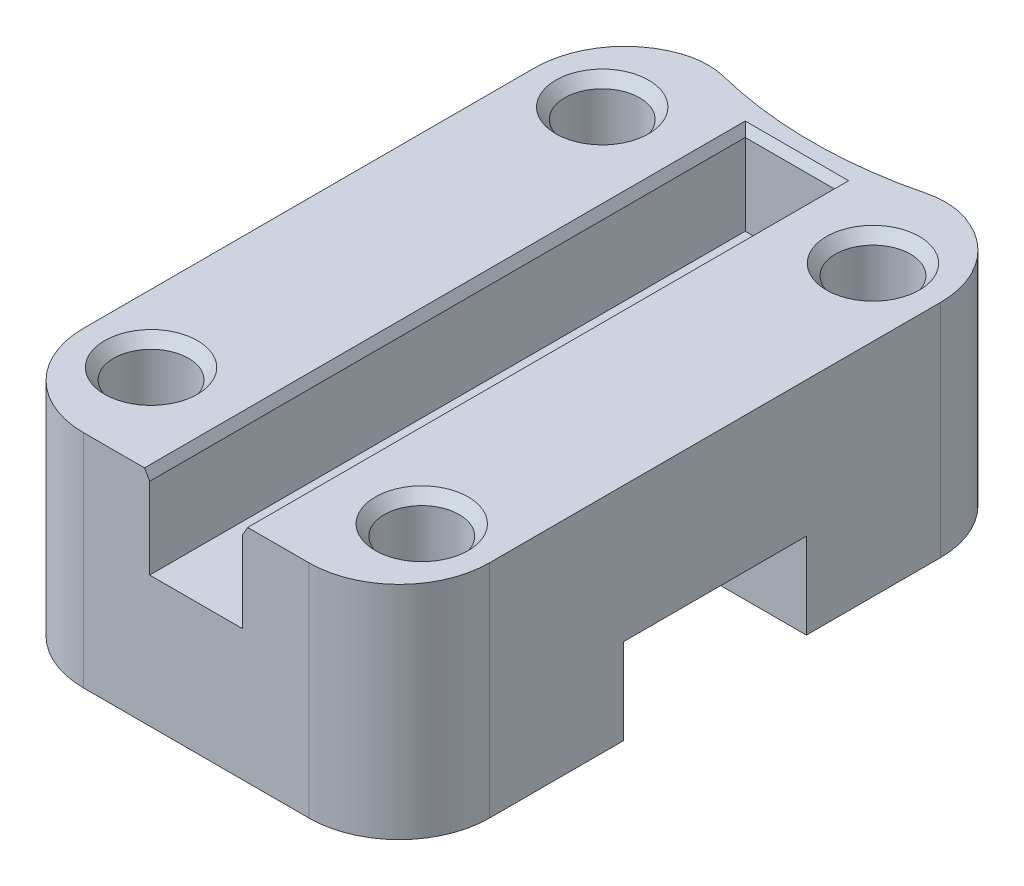
from build123d import *

# Parameters (mm, degrees)
SKETCH1_W               = 45
SKETCH1_H               = 70
BOSS_EXTRUDE1_DEPTH     = 14.5
SKETCH2_W               = 20.25
SKETCH2_H               = 9.5
CUT_EXTRUDE1_DEPTH      = 1
CUT_EXTRUDE1_DEPTH_BACK = 46
SKETCH3_R               = 4.15
CUT_EXTRUDE2_DEPTH      = 15.5
SKETCH5_R               = 4.15
BOSS_EXTRUDE2_DEPTH     = 10
CHAMFER1_SIZE           = 1
CHAMFER1_SIZE2          = 1.191753593
CHAMFER2_SIZE           = 1
CHAMFER2_SIZE2          = 0.577350269
CHAMFER2_PART_2_SIZE    = 1
CHAMFER2_PART_2_SIZE2   = 0.577350269
CHAMFER2_PART_3_SIZE    = 1
CHAMFER2_PART_3_SIZE2   = 0.577350269
FILLET1_R               = 10
CUT_EXTRUDE3_DEPTH      = 25.5
FILLET2_R               = 8


with BuildPart() as part:
    # Sketch1 → Boss-Extrude1 (new body)
    with BuildSketch(Plane(origin=(0, 0, 0), x_dir=(1, 0, 0), z_dir=(0, 1, 0))):
        Rectangle(SKETCH1_W, SKETCH1_H)
    extrude(amount=BOSS_EXTRUDE1_DEPTH)

    # Sketch2 → Cut-Extrude1 (cut, two sides)
    with BuildSketch(Plane(origin=(22.5, 0, 0), x_dir=(0, 0, -1), z_dir=(1, 0, 0))) as cut_extrude1_sk:
        with Locations((0, 4.75)):
            Rectangle(SKETCH2_W, SKETCH2_H)
    extrude(amount=CUT_EXTRUDE1_DEPTH, mode=Mode.SUBTRACT)
    extrude(cut_extrude1_sk.sketch, amount=-CUT_EXTRUDE1_DEPTH_BACK, mode=Mode.SUBTRACT)

    # Sketch3 → Cut-Extrude2 (cut, through all)
    with BuildSketch(Plane.XZ):
        with Locations((15, 25)):
            Circle(SKETCH3_R)
        with Locations((15, -25)):
            Circle(SKETCH3_R)
        with Locations((-15, -25)):
            Circle(SKETCH3_R)
        with Locations((-15, 25)):
            Circle(SKETCH3_R)
    extrude(amount=-CUT_EXTRUDE2_DEPTH, mode=Mode.SUBTRACT)

    # Sketch5 → Boss-Extrude2 (add)
    with BuildSketch(Plane(origin=(0, 14.5, 0), x_dir=(1, 0, 0), z_dir=(0, 1, 0))):
        Polygon((-5.15, -35), (-22.5, -35), (-22.5, 35), (22.5, 35), (22.5, -35), (5.15, -35), (5.130229348, -34.949305848), (5.15, 31), (-5.15, 31), align=None)
        with Locations((-15, 25)):
            Circle(SKETCH5_R, mode=Mode.SUBTRACT)
        with Locations((15, 25)):
            Circle(SKETCH5_R, mode=Mode.SUBTRACT)
        with Locations((15, -25)):
            Circle(SKETCH5_R, mode=Mode.SUBTRACT)
        with Locations((-15, -25)):
            Circle(SKETCH5_R, mode=Mode.SUBTRACT)
    extrude(amount=BOSS_EXTRUDE2_DEPTH)

    # Chamfer1
    chamfer1_edges = [part.edges().sort_by_distance(p)[0] for p in [
        (-19.15, 24.5, -25),
        (10.85, 24.5, -25),
        (10.85, 24.5, 25),
        (-19.15, 24.5, 25),
    ]]
    chamfer1_side = [part.faces().sort_by_distance(p)[0] for p in [
        (-13.825, 24.5, 34.167834151),
    ]]
    chamfer(chamfer1_edges, length=CHAMFER1_SIZE, length2=CHAMFER1_SIZE2, reference=chamfer1_side[0])

    # Chamfer2
    chamfer2_edges = [part.edges().sort_by_distance(p)[0] for p in [
        (-5.15, 24.5, 2),
    ]]
    chamfer2_side = [part.faces().sort_by_distance(p)[0] for p in [
        (-5.15, 19.5, 2),
    ]]
    chamfer(chamfer2_edges, length=CHAMFER2_SIZE, length2=CHAMFER2_SIZE2, reference=chamfer2_side[0])

    # Chamfer2 part 2
    chamfer2_part_2_edges = [part.edges().sort_by_distance(p)[0] for p in [
        (0, 24.5, -31),
    ]]
    chamfer2_part_2_side = [part.faces().sort_by_distance(p)[0] for p in [
        (0, 19.5, -31),
    ]]
    chamfer(chamfer2_part_2_edges, length=CHAMFER2_PART_2_SIZE, length2=CHAMFER2_PART_2_SIZE2, reference=chamfer2_part_2_side[0])

    # Chamfer2 part 3
    chamfer2_part_3_edges = [part.edges().sort_by_distance(p)[0] for p in [
        (5.140114674, 24.5, 1.974652924),
    ]]
    chamfer2_part_3_side = [part.faces().sort_by_distance(p)[0] for p in [
        (5.140114674, 19.5, 1.974652924),
    ]]
    chamfer(chamfer2_part_3_edges, length=CHAMFER2_PART_3_SIZE, length2=CHAMFER2_PART_3_SIZE2, reference=chamfer2_part_3_side[0])

    # Fillet1
    fillet1_edges = [part.edges().sort_by_distance(p)[0] for p in [
        (-22.5, 12.25, -35),
        (22.5, 12.25, -35),
        (22.5, 12.25, 35),
        (-22.5, 12.25, 35),
    ]]
    fillet(fillet1_edges, radius=FILLET1_R)

    # Sketch6 → Cut-Extrude3 (cut, through all)
    with BuildSketch(Plane.XZ):
        with BuildLine():
            Line((12.5, -35), (-12.5, -35))
            ThreePointArc((-12.5, -35), (0, -33.26906369), (12.5, -35))
        make_face()
    extrude(amount=-CUT_EXTRUDE3_DEPTH, mode=Mode.SUBTRACT)

    # Fillet2
    fillet2_edges = [part.edges().sort_by_distance(p)[0] for p in [
        (12.5, 12.25, -35),
        (-12.5, 12.25, -35),
    ]]
    fillet(fillet2_edges, radius=FILLET2_R)


solid = part.part
